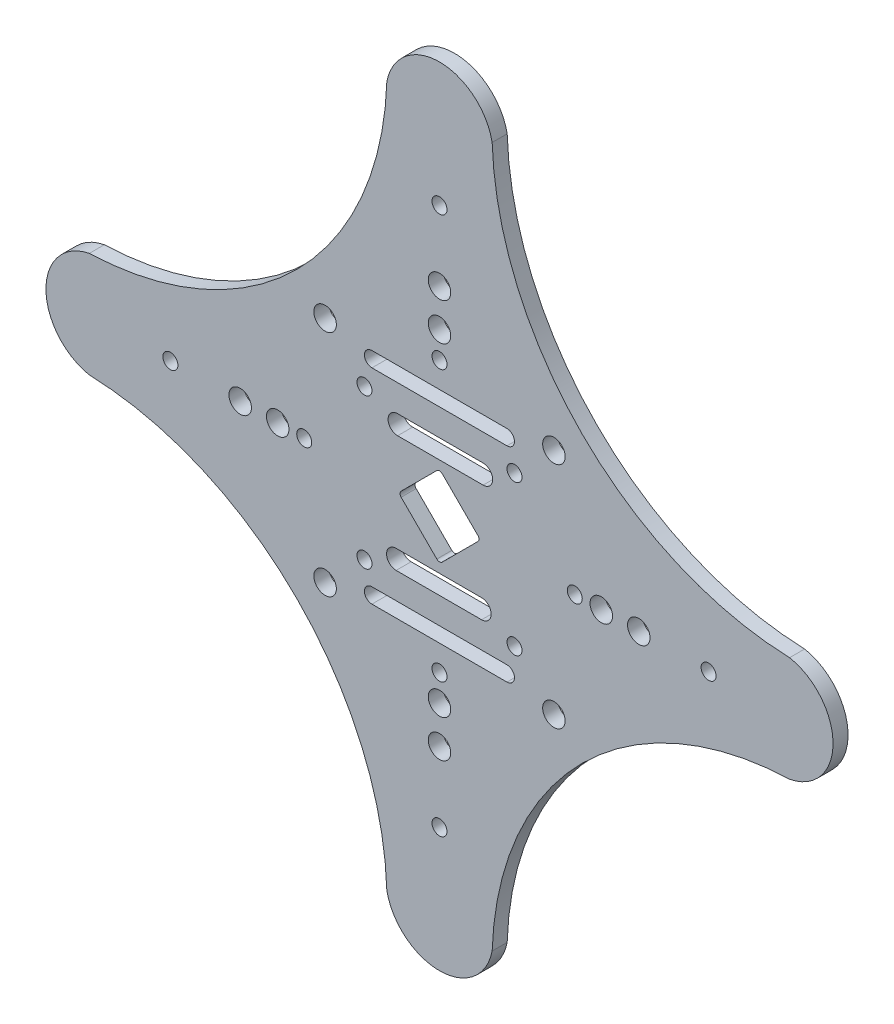
from build123d import *

# Parameters (mm, degrees)
MODEL_R         = 1
MODEL_R_2       = 1.5
EXTRUDE_1_DEPTH = 2


with BuildPart() as part:
    # Model → 凸台-拉伸1 (new body)
    with BuildSketch(Plane.XY):
        with BuildLine():
            ThreePointArc((165.794247794, 119.146851779), (178.48431443, 110.518191971), (193.458034411, 107.159729335))
            ThreePointArc((193.458034411, 107.159729335), (199.244879812, 100.139821501), (193.458034411, 93.119913668))
            ThreePointArc((193.458034411, 93.119913668), (178.48431443, 89.761451032), (165.794247794, 81.132791223))
            ThreePointArc((165.794247794, 81.132791223), (157.165587985, 68.442724587), (153.807125349, 53.469004606))
            ThreePointArc((153.807125349, 53.469004606), (146.787217515, 47.682159205), (139.767309682, 53.469004606))
            ThreePointArc((139.767309682, 53.469004606), (136.408847046, 68.442724587), (127.780187237, 81.132791223))
            ThreePointArc((127.780187237, 81.132791223), (115.090120601, 89.761451032), (100.11640062, 93.119913668))
            ThreePointArc((100.11640062, 93.119913668), (94.329555219, 100.139821501), (100.11640062, 107.159729335))
            ThreePointArc((100.11640062, 107.159729335), (115.090120601, 110.518191971), (127.780187237, 119.146851779))
            ThreePointArc((127.780187237, 119.146851779), (136.408847046, 131.836918416), (139.767309682, 146.810638396))
            ThreePointArc((139.767309682, 146.810638396), (146.787217515, 152.597483797), (153.807125349, 146.810638396))
            ThreePointArc((153.807125349, 146.810638396), (157.165587985, 131.836918416), (165.794247794, 119.146851779))
        make_face()
        with Locations((156.787217515, 110.139821501)):
            Circle(MODEL_R, mode=Mode.SUBTRACT)
        with Locations((136.787217515, 110.139821501)):
            Circle(MODEL_R, mode=Mode.SUBTRACT)
        with Locations((136.787217515, 90.139821501)):
            Circle(MODEL_R, mode=Mode.SUBTRACT)
        with Locations((156.787217515, 90.139821501)):
            Circle(MODEL_R, mode=Mode.SUBTRACT)
        with Locations((168.353974342, 100.139821501)):
            Circle(MODEL_R_2, mode=Mode.SUBTRACT)
        with Locations((146.787217515, 121.706578327)):
            Circle(MODEL_R_2, mode=Mode.SUBTRACT)
        with Locations((125.220460689, 100.139821501)):
            Circle(MODEL_R_2, mode=Mode.SUBTRACT)
        with Locations((146.787217515, 78.573064675)):
            Circle(MODEL_R_2, mode=Mode.SUBTRACT)
        with Locations((146.787217515, 126.706578327)):
            Circle(MODEL_R_2, mode=Mode.SUBTRACT)
        with Locations((120.220460689, 100.139821501)):
            Circle(MODEL_R_2, mode=Mode.SUBTRACT)
        with Locations((146.787217515, 73.573064675)):
            Circle(MODEL_R_2, mode=Mode.SUBTRACT)
        with Locations((173.353974342, 100.139821501)):
            Circle(MODEL_R_2, mode=Mode.SUBTRACT)
        with Locations((146.787217515, 118.171044401)):
            Circle(MODEL_R, mode=Mode.SUBTRACT)
        with Locations((128.755994615, 100.139821501)):
            Circle(MODEL_R, mode=Mode.SUBTRACT)
        with Locations((146.787217515, 82.108598601)):
            Circle(MODEL_R, mode=Mode.SUBTRACT)
        with Locations((164.818440415, 100.139821501)):
            Circle(MODEL_R, mode=Mode.SUBTRACT)
        with Locations((162.037217515, 115.389821501)):
            Circle(MODEL_R_2, mode=Mode.SUBTRACT)
        with Locations((131.537217515, 115.389821501)):
            Circle(MODEL_R_2, mode=Mode.SUBTRACT)
        with Locations((131.537217515, 84.889821501)):
            Circle(MODEL_R_2, mode=Mode.SUBTRACT)
        with Locations((162.037217515, 84.889821501)):
            Circle(MODEL_R_2, mode=Mode.SUBTRACT)
        with Locations((182.657217515, 100.139821501)):
            Circle(MODEL_R, mode=Mode.SUBTRACT)
        with Locations((146.787217515, 136.036864466)):
            Circle(MODEL_R, mode=Mode.SUBTRACT)
        with Locations((110.917217515, 100.139821501)):
            Circle(MODEL_R, mode=Mode.SUBTRACT)
        with Locations((146.787217515, 64.242778536)):
            Circle(MODEL_R, mode=Mode.SUBTRACT)
        with BuildLine():
            Line((152.398515146, 91.006916148), (141.004728844, 91.006916149))
            ThreePointArc((141.004728844, 91.006916149), (140.104214379, 91.379921453), (139.731209075, 92.280435918))
            ThreePointArc((139.731209075, 92.280435918), (140.104214379, 93.180950383), (141.004728844, 93.553955688))
            Line((141.004728844, 93.553955688), (152.398515146, 93.553955687))
            ThreePointArc((152.398515146, 93.553955687), (153.672034916, 92.280435917), (152.398515146, 91.006916148))
        make_face(mode=Mode.SUBTRACT)
        with BuildLine():
            Line((152.599718137, 109.199272945), (141.205931835, 109.199272945))
            ThreePointArc((141.205931835, 109.199272945), (140.30541737, 108.826267641), (139.932412066, 107.925753176))
            ThreePointArc((139.932412066, 107.925753176), (140.30541737, 107.025238711), (141.205931835, 106.652233406))
            Line((141.205931835, 106.652233406), (152.599718137, 106.652233406))
            ThreePointArc((152.599718137, 106.652233406), (153.873237907, 107.925753176), (152.599718137, 109.199272945))
        make_face(mode=Mode.SUBTRACT)
        with BuildLine():
            Line((151.898560909, 100.493374892), (147.140770906, 105.251164895))
            ThreePointArc((147.140770906, 105.251164895), (146.787217515, 105.397611504), (146.433664125, 105.251164895))
            Line((146.433664125, 105.251164895), (141.675874122, 100.493374892))
            ThreePointArc((141.675874122, 100.493374892), (141.529427512, 100.139821501), (141.675874122, 99.786268111))
            Line((141.675874122, 99.786268111), (146.433664125, 95.028478108))
            ThreePointArc((146.433664125, 95.028478108), (146.787217515, 94.882031498), (147.140770906, 95.028478108))
            Line((147.140770906, 95.028478108), (151.898560909, 99.786268111))
            ThreePointArc((151.898560909, 99.786268111), (152.045007518, 100.139821501), (151.898560909, 100.493374892))
        make_face(mode=Mode.SUBTRACT)
        with BuildLine():
            Line((137.779884988, 87.503468035), (155.779884988, 87.503468035))
            ThreePointArc((155.779884988, 87.503468035), (156.779884988, 86.503468035), (155.779884988, 85.503468035))
            Line((155.779884988, 85.503468035), (137.779884988, 85.503468035))
            ThreePointArc((137.779884988, 85.503468035), (137.072778206, 85.796361253), (136.779884988, 86.503468035))
            ThreePointArc((136.779884988, 86.503468035), (137.072778206, 87.210574816), (137.779884988, 87.503468035))
        make_face(mode=Mode.SUBTRACT)
        with BuildLine():
            Line((137.779884988, 112.776174968), (155.779884988, 112.776174968))
            ThreePointArc((155.779884988, 112.776174968), (156.779884988, 113.776174968), (155.779884988, 114.776174968))
            Line((155.779884988, 114.776174968), (137.779884988, 114.776174968))
            ThreePointArc((137.779884988, 114.776174968), (137.072778206, 114.483281749), (136.779884988, 113.776174968))
            ThreePointArc((136.779884988, 113.776174968), (137.072778206, 113.069068187), (137.779884988, 112.776174968))
        make_face(mode=Mode.SUBTRACT)
    extrude(amount=EXTRUDE_1_DEPTH)


solid = part.part
